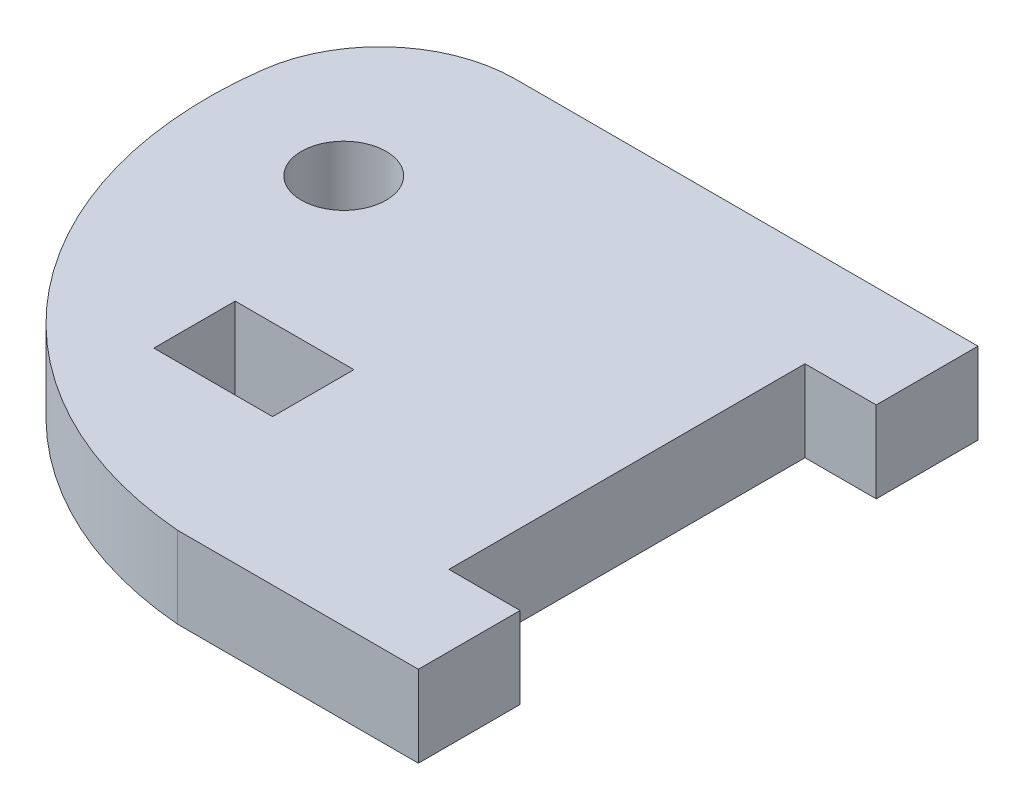
from build123d import *

# Parameters (mm, degrees)
SKETCH1_R           = 3.175
SKETCH1_W           = 8.89
SKETCH1_H           = 6.096
BOSS_EXTRUDE1_DEPTH = 3.048


with BuildPart() as part:
    # Sketch1 → Boss-Extrude1 (new, symmetric)
    with BuildSketch(Plane(origin=(0, 0, 0), x_dir=(1, 0, 0), z_dir=(0, 1, 0))):
        with BuildLine():
            Line((29.464, -21.59), (29.464, 5.08))
            Line((29.464, 5.08), (34.798, 5.08))
            Line((34.798, 5.08), (34.798, 12.7))
            Line((34.798, 12.7), (0.169222866, 12.7))
            ThreePointArc((0.169222866, 12.7), (-6.521515016, 10.185889524), (-9.900982384, 3.887800513))
            ThreePointArc((-9.900982384, 3.887800513), (-3.674965137, -18.386374523), (16.764, -29.21))
            Line((16.764, -29.21), (34.798, -29.21))
            Line((34.798, -29.21), (34.798, -21.59))
            Line((34.798, -21.59), (29.464, -21.59))
        make_face()
        Circle(SKETCH1_R, mode=Mode.SUBTRACT)
        with Locations((8.509, -15.24)):
            Rectangle(SKETCH1_W, SKETCH1_H, mode=Mode.SUBTRACT)
    extrude(amount=BOSS_EXTRUDE1_DEPTH, both=True)


solid = part.part
